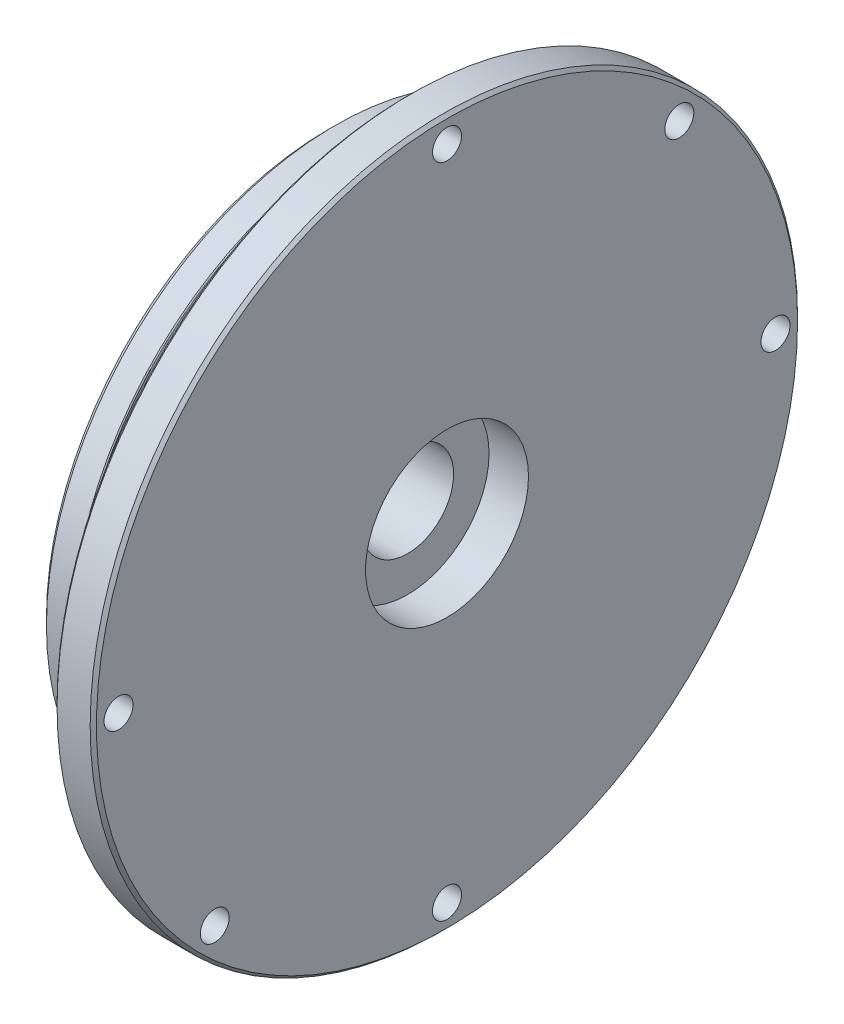
from build123d import *

# Parameters (mm, degrees)
M3_CLEARANCE_HOLE1_D                     = 3.5052
M3_CLEARANCE_HOLE1_DEPTH                 = 4.7625
CBORE_FOR_M10_HEX_HEAD_BOLT1_D           = 11.1125
CBORE_FOR_M10_HEX_HEAD_BOLT1_DEPTH       = 14.2875
CBORE_FOR_M10_HEX_HEAD_BOLT1_CBORE_D     = 19.685
CBORE_FOR_M10_HEX_HEAD_BOLT1_CBORE_DEPTH = 4.7625
CHAMFER1_SIZE                            = 0.381
CHAMFER2_SIZE                            = 0.7874
FILLET1_R                                = 0.127
FILLET2_R                                = 0.381


with BuildPart() as part:
    # Sketch1 → Revolve1 (revolve)
    with BuildSketch(Plane(origin=(0, 0, 0), x_dir=(-1, 0, 0), z_dir=(0, 0, -1))):
        Polygon((-14.2875, 42.7355), (-14.2875, 0), (0, 0), (0, 34.8996), (-3.937, 34.8996), (-3.937, 33.655), (-6.35, 33.655), (-6.35, 34.8996), (-9.525, 34.8996), (-9.525, 42.7355), align=None)
    revolve(axis=Axis((14.2875, 0, 0), (-1, 0, 0)))

    # M3 Clearance Hole1
    with Locations(Plane.ZY.offset(-9.525)):
        with Locations((28.063300378, -28.063300378), (-28.063300378, 28.063300378), (39.6875, 0), (-39.6875, 0), (0, -39.6875), (0, 39.6875)):
            Hole(M3_CLEARANCE_HOLE1_D / 2, depth=M3_CLEARANCE_HOLE1_DEPTH)

    # CBORE for M10 Hex Head Bolt1
    with Locations(Plane(origin=(14.2875, 0, 0), x_dir=(0, 0, -1), z_dir=(1, 0, 0))):
        with Locations((0, 0)):
            CounterBoreHole(CBORE_FOR_M10_HEX_HEAD_BOLT1_D / 2, CBORE_FOR_M10_HEX_HEAD_BOLT1_CBORE_D / 2, CBORE_FOR_M10_HEX_HEAD_BOLT1_CBORE_DEPTH, depth=CBORE_FOR_M10_HEX_HEAD_BOLT1_DEPTH)

    # Chamfer1
    chamfer1_edges = [part.edges().sort_by_distance(p)[0] for p in [
        (14.2875, -42.7355, 0),
        (9.525, -42.7355, 0),
    ]]
    chamfer(chamfer1_edges, length=CHAMFER1_SIZE)

    # Chamfer2
    chamfer2_edges = [part.edges().sort_by_distance(p)[0] for p in [
        (0, -34.8996, 0),
    ]]
    chamfer(chamfer2_edges, length=CHAMFER2_SIZE)

    # Fillet1
    fillet1_edges = [part.edges().sort_by_distance(p)[0] for p in [
        (6.35, -34.8996, 0),
        (3.937, -34.8996, 0),
    ]]
    fillet(fillet1_edges, radius=FILLET1_R)

    # Fillet2
    fillet2_edges = [part.edges().sort_by_distance(p)[0] for p in [
        (6.35, -33.655, 0),
        (3.937, -33.655, 0),
    ]]
    fillet(fillet2_edges, radius=FILLET2_R)


solid = part.part
